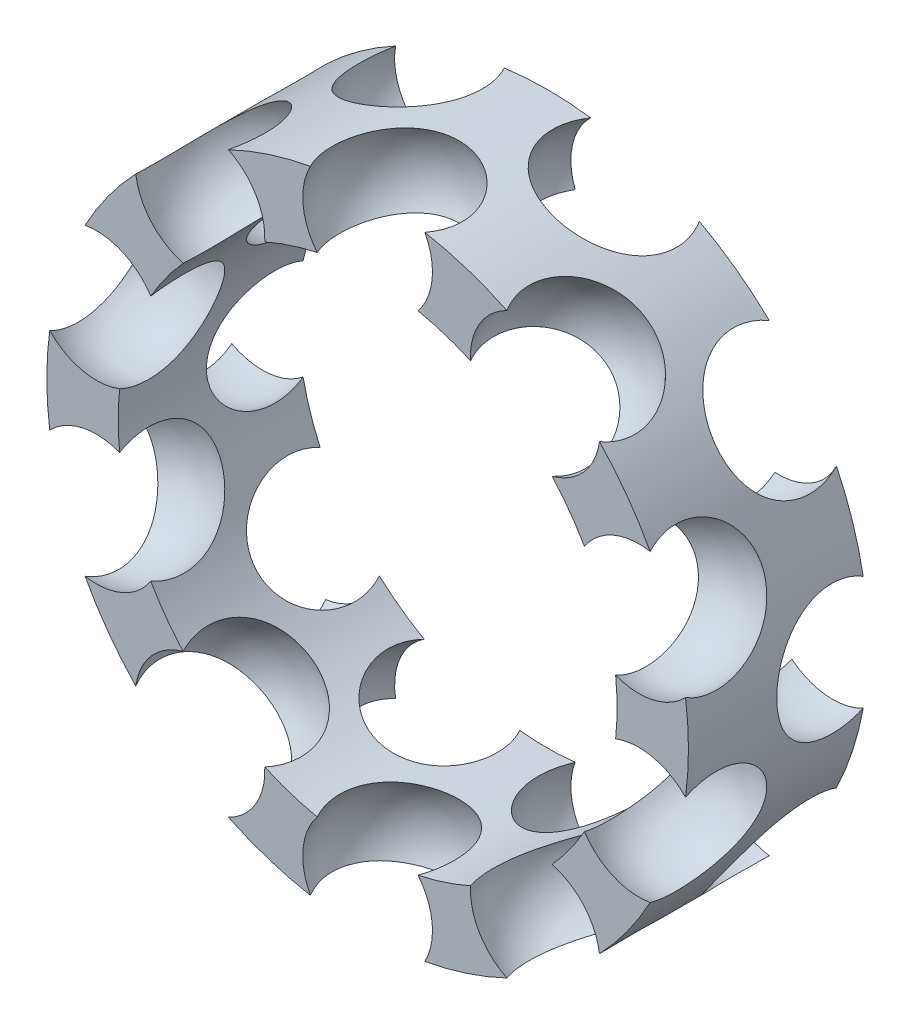
from build123d import *

# Parameters (mm, degrees)
SKETCH_1_W               = 4.5
SKETCH_1_H               = 1.625
PATTERN_CIRCULAR_1_COUNT = 10
PATTERN_CIRCULAR_2_COUNT = 10
SKETCH_4_R               = 7.3125
CUT_EXTRUDE_1_DEPTH      = 0.2


with BuildPart() as part:
    # Эскиз1 → Повернуть1 (revolve)
    with BuildSketch(Plane(origin=(0, 0, 0), x_dir=(0, 0, -1), z_dir=(1, 0, 0))):
        with Locations((2.25, 6.5)):
            Rectangle(SKETCH_1_W, SKETCH_1_H)
    revolve(axis=Axis((0, 0, 0), (0, 0, -1)))

    # Эскиз2 → Вырез-Повернуть1 (revolve, cut)
    with BuildSketch(Plane(origin=(0, 6.5, 0), x_dir=(1, 0, 0), z_dir=(0, 1, 0))):
        with BuildLine():
            Line((0, 2.5), (0, -0.75))
            ThreePointArc((0, -0.75), (1.625, 0.875), (0, 2.5))
        make_face()
    cut_revolve_1 = revolve(axis=Axis((0, 6.5, -2.5), (0, 0, 1)), mode=Mode.SUBTRACT)

    # Круговой массив1: Вырез-Повернуть1 ×10 about axis
    pattern_circular_1_axis = Axis((0, 0, 0), (0, 0, 1))
    for i in range(1, PATTERN_CIRCULAR_1_COUNT):
        add(cut_revolve_1.rotate(pattern_circular_1_axis, i * 360 / PATTERN_CIRCULAR_1_COUNT), mode=Mode.SUBTRACT)

    # Эскиз3 → Вырез-Повернуть2 (revolve, cut)
    with BuildSketch(Plane(origin=(-2.008610463, 6.181867356, 0), x_dir=(0, 0, 1), z_dir=(-0.309016994, 0.951056516, 0))):
        with BuildLine():
            Line((-5.245, 0), (-1.995, 0))
            ThreePointArc((-1.995, 0), (-3.62, 1.625), (-5.245, 0))
        make_face()
    cut_revolve_2 = revolve(axis=Axis((-2.008610463, 6.181867356, -5.245), (0, 0, 1)), mode=Mode.SUBTRACT)

    # Круговой массив2: Вырез-Повернуть2 ×10 about axis
    pattern_circular_2_axis = Axis((0, 0, 0), (0, 0, 1))
    for i in range(1, PATTERN_CIRCULAR_2_COUNT):
        add(cut_revolve_2.rotate(pattern_circular_2_axis, i * 360 / PATTERN_CIRCULAR_2_COUNT), mode=Mode.SUBTRACT)

    # Эскиз4 → Вырез-Вытянуть1 (cut)
    with BuildSketch(Plane.XY):
        Circle(SKETCH_4_R)
    cut_extrude_1 = extrude(amount=-CUT_EXTRUDE_1_DEPTH, mode=Mode.SUBTRACT)

    # Зеркальное отражение1: Вырез-Вытянуть1 across plane
    add(cut_extrude_1.mirror(Plane.XY.offset(-2.25)), mode=Mode.SUBTRACT)


solid = part.part
